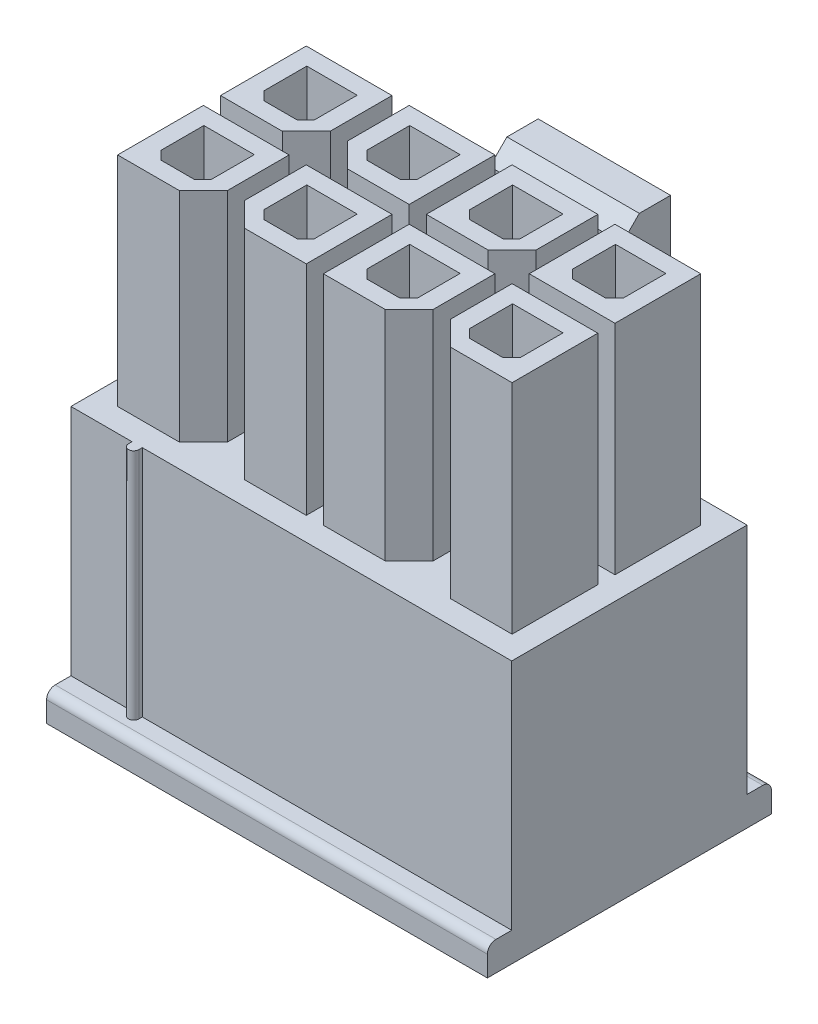
from build123d import *

# Parameters (mm, degrees)
SKETCH1_W            = 12.85
SKETCH1_H            = 7.65
BOSS_EXTRUDE1_DEPTH  = 7.57
SKETCH2_W            = 3.86
SKETCH2_H            = 0.91
BOSS_EXTRUDE2_DEPTH  = 3.28
SKETCH3_W            = 3.86
SKETCH3_H            = 2.43
BOSS_EXTRUDE3_DEPTH  = 6.09
SKETCH4_W            = 3.86
SKETCH4_H            = 2.43
BOSS_EXTRUDE4_DEPTH  = 4
SKETCH5_W            = 1.02
SKETCH5_H            = 9.5
CUT_EXTRUDE1_DEPTH   = 9.35
SKETCH6_W            = 0.71
SKETCH6_H            = 6.8
CUT_EXTRUDE2_DEPTH   = 13.85
BOSS_EXTRUDE5_DEPTH  = 6.8
SKETCH8_W            = 3.69
SKETCH8_H            = 0.85
BOSS_EXTRUDE6_DEPTH  = 0.71
SKETCH9_W            = 3.7
SKETCH9_H            = 0.85
BOSS_EXTRUDE7_DEPTH  = 0.71
SKETCH10_W           = 2.5
SKETCH10_H           = 2.5
BOSS_EXTRUDE8_DEPTH  = 6.35
SKETCH11_W           = 1.47
SKETCH11_H           = 1.5
CUT_EXTRUDE3_DEPTH   = 5.8
SKETCH12_W           = 2.5
SKETCH12_H           = 2.5
BOSS_EXTRUDE9_DEPTH  = 6.35
SKETCH13_W           = 1.47
SKETCH13_H           = 1.5
CUT_EXTRUDE4_DEPTH   = 5.8
SKETCH14_W           = 2.5
SKETCH14_H           = 2.5
BOSS_EXTRUDE10_DEPTH = 6.35
SKETCH15_W           = 1.47
SKETCH15_H           = 1.5
CUT_EXTRUDE5_DEPTH   = 5.8
SKETCH16_W           = 2.5
SKETCH16_H           = 2.5
BOSS_EXTRUDE11_DEPTH = 6.35
SKETCH17_W           = 1.47
SKETCH17_H           = 1.5
CUT_EXTRUDE6_DEPTH   = 5.8
SKETCH18_W           = 2.5
SKETCH18_H           = 2.5
BOSS_EXTRUDE12_DEPTH = 6.35
SKETCH19_W           = 1.47
SKETCH19_H           = 1.5
CUT_EXTRUDE7_DEPTH   = 5.8
SKETCH20_W           = 2.5
SKETCH20_H           = 2.5
BOSS_EXTRUDE13_DEPTH = 6.35
SKETCH21_W           = 1.47
SKETCH21_H           = 1.5
CUT_EXTRUDE8_DEPTH   = 5.8
SKETCH22_W           = 2.5
SKETCH22_H           = 2.5
BOSS_EXTRUDE14_DEPTH = 6.35
SKETCH23_W           = 1.47
SKETCH23_H           = 1.5
CUT_EXTRUDE9_DEPTH   = 5.8
SKETCH24_W           = 2.5
SKETCH24_H           = 2.5
BOSS_EXTRUDE15_DEPTH = 6.35
SKETCH25_W           = 1.47
SKETCH25_H           = 1.5
CUT_EXTRUDE10_DEPTH  = 5.8
DRAFT1_ANGLE         = 36.326825952
CHAMFER1_SIZE        = 0.25
CHAMFER2_SIZE        = 0.7
CHAMFER3_SIZE        = 0.5
FILLET1_R            = 0.25
FILLET2_R            = 0.5


with BuildPart() as part:
    # Sketch1 → Boss-Extrude1 (new body)
    with BuildSketch(Plane.XY.offset(4.14)):
        with Locations((-0.005, -0.175)):
            Rectangle(SKETCH1_W, SKETCH1_H)
    extrude(amount=-BOSS_EXTRUDE1_DEPTH)

    # Sketch2 → Boss-Extrude2 (add)
    with BuildSketch(Plane(origin=(0, 0, -3.43), x_dir=(-1, 0, 0), z_dir=(0, 0, -1))):
        with Locations((0, 2.055)):
            Rectangle(SKETCH2_W, SKETCH2_H)
    extrude(amount=BOSS_EXTRUDE2_DEPTH)

    # Sketch3 → Boss-Extrude3 (add)
    with BuildSketch(Plane(origin=(0, 2.51, 0), x_dir=(-1, 0, 0), z_dir=(0, 1, 0))):
        with Locations((0, -5.495)):
            Rectangle(SKETCH3_W, SKETCH3_H)
    extrude(amount=BOSS_EXTRUDE3_DEPTH)

    # Sketch4 → Boss-Extrude4 (add)
    with BuildSketch(Plane.XZ.offset(-1.6)):
        with Locations((0, -5.495)):
            Rectangle(SKETCH4_W, SKETCH4_H)
    extrude(amount=BOSS_EXTRUDE4_DEPTH)

    # Sketch5 → Cut-Extrude1 (cut, through all)
    with BuildSketch(Plane.ZY.offset(1.93)):
        with Locations((-6.2, 3.85)):
            Rectangle(SKETCH5_W, SKETCH5_H)
    extrude(amount=-CUT_EXTRUDE1_DEPTH, mode=Mode.SUBTRACT)

    # Sketch6 → Cut-Extrude2 (cut, through all)
    with BuildSketch(Plane(origin=(6.42, 0, 0), x_dir=(0, 0, -1), z_dir=(1, 0, 0))):
        with Locations((-3.785, 0.25)):
            Rectangle(SKETCH6_W, SKETCH6_H)
    extrude(amount=-CUT_EXTRUDE2_DEPTH, mode=Mode.SUBTRACT)

    # Sketch7 → Boss-Extrude5 (add)
    with BuildSketch(Plane(origin=(0, -3.15, 0), x_dir=(-1, 0, 0), z_dir=(0, 1, 0))):
        with BuildLine():
            Line((4.35, 3.43), (4.35, 3.53))
            ThreePointArc((4.35, 3.53), (4.5, 3.68), (4.65, 3.53))
            Line((4.65, 3.53), (4.65, 3.43))
            Line((4.65, 3.43), (4.35, 3.43))
        make_face()
    extrude(amount=BOSS_EXTRUDE5_DEPTH)

    # Sketch8 → Boss-Extrude6 (add)
    with BuildSketch(Plane(origin=(0, 0, -3.43), x_dir=(-1, 0, 0), z_dir=(0, 0, -1))):
        with Locations((-4.575, -3.575)):
            Rectangle(SKETCH8_W, SKETCH8_H)
    extrude(amount=BOSS_EXTRUDE6_DEPTH)

    # Sketch9 → Boss-Extrude7 (add)
    with BuildSketch(Plane(origin=(0, 0, -3.43), x_dir=(-1, 0, 0), z_dir=(0, 0, -1))):
        with Locations((4.58, -3.575)):
            Rectangle(SKETCH9_W, SKETCH9_H)
    extrude(amount=BOSS_EXTRUDE7_DEPTH)

    # Sketch10 → Boss-Extrude8 (add)
    with BuildSketch(Plane(origin=(0, 3.65, 0), x_dir=(-1, 0, 0), z_dir=(0, 1, 0))):
        with Locations((4.5, -1.5)):
            Rectangle(SKETCH10_W, SKETCH10_H)
    extrude(amount=BOSS_EXTRUDE8_DEPTH)

    # Sketch11 → Cut-Extrude3 (cut)
    with BuildSketch(Plane(origin=(0, 10, 0), x_dir=(-1, 0, 0), z_dir=(0, 1, 0))):
        with Locations((4.5, -1.5)):
            Rectangle(SKETCH11_W, SKETCH11_H)
    extrude(amount=-CUT_EXTRUDE3_DEPTH, mode=Mode.SUBTRACT)

    # Sketch12 → Boss-Extrude9 (add)
    with BuildSketch(Plane(origin=(0, 3.65, 0), x_dir=(-1, 0, 0), z_dir=(0, 1, 0))):
        with Locations((4.5, 1.5)):
            Rectangle(SKETCH12_W, SKETCH12_H)
    extrude(amount=BOSS_EXTRUDE9_DEPTH)

    # Sketch13 → Cut-Extrude4 (cut)
    with BuildSketch(Plane(origin=(0, 10, 0), x_dir=(-1, 0, 0), z_dir=(0, 1, 0))):
        with Locations((4.5, 1.5)):
            Rectangle(SKETCH13_W, SKETCH13_H)
    extrude(amount=-CUT_EXTRUDE4_DEPTH, mode=Mode.SUBTRACT)

    # Sketch14 → Boss-Extrude10 (add)
    with BuildSketch(Plane(origin=(0, 3.65, 0), x_dir=(-1, 0, 0), z_dir=(0, 1, 0))):
        with Locations((1.5, 1.5)):
            Rectangle(SKETCH14_W, SKETCH14_H)
    extrude(amount=BOSS_EXTRUDE10_DEPTH)

    # Sketch15 → Cut-Extrude5 (cut)
    with BuildSketch(Plane(origin=(0, 10, 0), x_dir=(-1, 0, 0), z_dir=(0, 1, 0))):
        with Locations((1.5, 1.5)):
            Rectangle(SKETCH15_W, SKETCH15_H)
    extrude(amount=-CUT_EXTRUDE5_DEPTH, mode=Mode.SUBTRACT)

    # Sketch16 → Boss-Extrude11 (add)
    with BuildSketch(Plane(origin=(0, 3.65, 0), x_dir=(-1, 0, 0), z_dir=(0, 1, 0))):
        with Locations((1.5, -1.5)):
            Rectangle(SKETCH16_W, SKETCH16_H)
    extrude(amount=BOSS_EXTRUDE11_DEPTH)

    # Sketch17 → Cut-Extrude6 (cut)
    with BuildSketch(Plane(origin=(0, 10, 0), x_dir=(-1, 0, 0), z_dir=(0, 1, 0))):
        with Locations((1.5, -1.5)):
            Rectangle(SKETCH17_W, SKETCH17_H)
    extrude(amount=-CUT_EXTRUDE6_DEPTH, mode=Mode.SUBTRACT)

    # Sketch18 → Boss-Extrude12 (add)
    with BuildSketch(Plane(origin=(0, 3.65, 0), x_dir=(-1, 0, 0), z_dir=(0, 1, 0))):
        with Locations((-1.5, -1.5)):
            Rectangle(SKETCH18_W, SKETCH18_H)
    extrude(amount=BOSS_EXTRUDE12_DEPTH)

    # Sketch19 → Cut-Extrude7 (cut)
    with BuildSketch(Plane(origin=(0, 10, 0), x_dir=(-1, 0, 0), z_dir=(0, 1, 0))):
        with Locations((-1.5, -1.5)):
            Rectangle(SKETCH19_W, SKETCH19_H)
    extrude(amount=-CUT_EXTRUDE7_DEPTH, mode=Mode.SUBTRACT)

    # Sketch20 → Boss-Extrude13 (add)
    with BuildSketch(Plane(origin=(0, 3.65, 0), x_dir=(-1, 0, 0), z_dir=(0, 1, 0))):
        with Locations((-1.5, 1.5)):
            Rectangle(SKETCH20_W, SKETCH20_H)
    extrude(amount=BOSS_EXTRUDE13_DEPTH)

    # Sketch21 → Cut-Extrude8 (cut)
    with BuildSketch(Plane(origin=(0, 10, 0), x_dir=(-1, 0, 0), z_dir=(0, 1, 0))):
        with Locations((-1.5, 1.5)):
            Rectangle(SKETCH21_W, SKETCH21_H)
    extrude(amount=-CUT_EXTRUDE8_DEPTH, mode=Mode.SUBTRACT)

    # Sketch22 → Boss-Extrude14 (add)
    with BuildSketch(Plane(origin=(0, 3.65, 0), x_dir=(-1, 0, 0), z_dir=(0, 1, 0))):
        with Locations((-4.5, 1.5)):
            Rectangle(SKETCH22_W, SKETCH22_H)
    extrude(amount=BOSS_EXTRUDE14_DEPTH)

    # Sketch23 → Cut-Extrude9 (cut)
    with BuildSketch(Plane(origin=(0, 10, 0), x_dir=(-1, 0, 0), z_dir=(0, 1, 0))):
        with Locations((-4.5, 1.5)):
            Rectangle(SKETCH23_W, SKETCH23_H)
    extrude(amount=-CUT_EXTRUDE9_DEPTH, mode=Mode.SUBTRACT)

    # Sketch24 → Boss-Extrude15 (add)
    with BuildSketch(Plane(origin=(0, 3.65, 0), x_dir=(-1, 0, 0), z_dir=(0, 1, 0))):
        with Locations((-4.5, -1.5)):
            Rectangle(SKETCH24_W, SKETCH24_H)
    extrude(amount=BOSS_EXTRUDE15_DEPTH)

    # Sketch25 → Cut-Extrude10 (cut)
    with BuildSketch(Plane(origin=(0, 10, 0), x_dir=(-1, 0, 0), z_dir=(0, 1, 0))):
        with Locations((-4.5, -1.5)):
            Rectangle(SKETCH25_W, SKETCH25_H)
    extrude(amount=-CUT_EXTRUDE10_DEPTH, mode=Mode.SUBTRACT)

    # Draft1
    draft1_faces = [part.faces().sort_by_distance(p)[0] for p in [
        (0, -0.9, -6.2),
    ]]
    draft(draft1_faces, Plane(origin=(6.42, -0.9, -5.69), x_dir=(-1, 0, 0), z_dir=(0, 0, -1)), DRAFT1_ANGLE)

    # Chamfer1
    chamfer1_edges = [part.edges().sort_by_distance(p)[0] for p in [
        (-3.765, 7.1, -0.75),
        (-5.235, 7.1, -0.75),
        (-3.765, 7.1, 2.25),
        (-5.235, 7.1, 2.25),
        (-0.765, 7.1, 2.25),
        (-2.235, 7.1, 2.25),
        (-0.765, 7.1, -0.75),
        (-2.235, 7.1, -0.75),
        (2.235, 7.1, -0.75),
        (0.765, 7.1, -0.75),
        (2.235, 7.1, 2.25),
        (0.765, 7.1, 2.25),
        (5.235, 7.1, 2.25),
        (3.765, 7.1, 2.25),
        (5.235, 7.1, -0.75),
        (3.765, 7.1, -0.75),
    ]]
    chamfer(chamfer1_edges, length=CHAMFER1_SIZE)

    # Chamfer2
    chamfer2_edges = [part.edges().sort_by_distance(p)[0] for p in [
        (-3.25, 6.825, -0.25),
        (-3.25, 6.825, 2.75),
        (-2.75, 6.825, 2.75),
        (-2.75, 6.825, -0.25),
        (2.75, 6.825, -0.25),
        (2.75, 6.825, 2.75),
        (3.25, 6.825, 2.75),
    ]]
    chamfer(chamfer2_edges, length=CHAMFER2_SIZE)

    # Chamfer3
    chamfer3_edges = [part.edges().sort_by_distance(p)[0] for p in [
        (0, 8.6, -4.28),
    ]]
    chamfer(chamfer3_edges, length=CHAMFER3_SIZE)

    # Fillet1
    fillet1_edges = [part.edges().sort_by_distance(p)[0] for p in [
        (4.575, -3.15, -4.14),
        (-4.58, -3.15, -4.14),
        (-1.93, 2.055, -3.43),
        (1.93, 2.055, -3.43),
        (-0.005, -3.15, 4.14),
    ]]
    fillet(fillet1_edges, radius=FILLET1_R)

    # Fillet2
    fillet2_edges = [part.edges().sort_by_distance(p)[0] for p in [
        (0, 2.51, -4.28),
        (0, 1.6, -4.28),
    ]]
    fillet(fillet2_edges, radius=FILLET2_R)


solid = part.part
